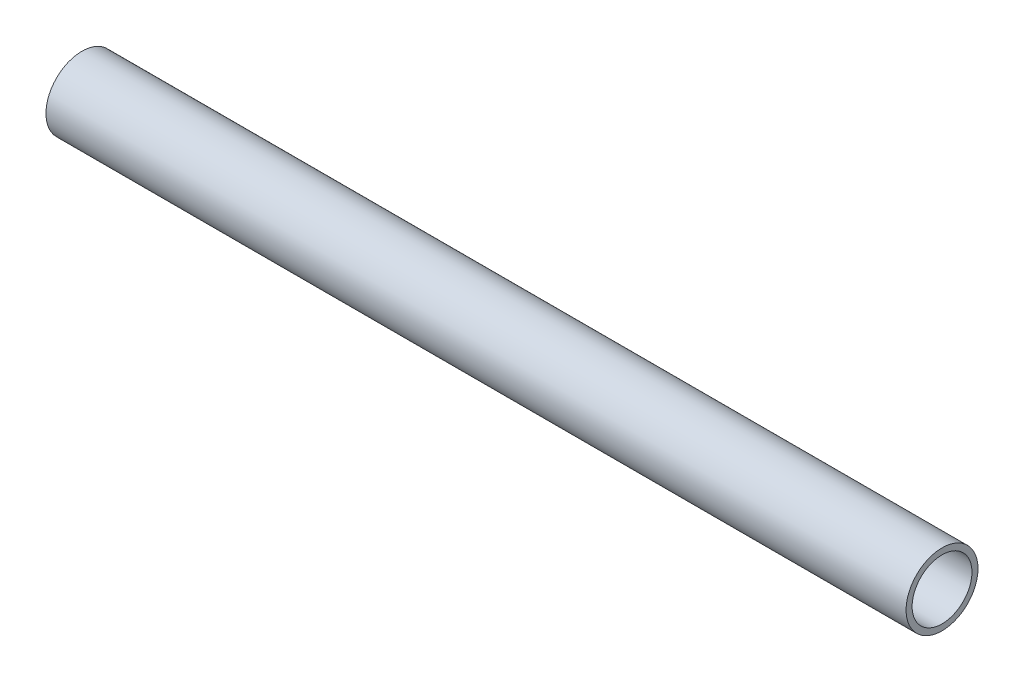
from build123d import *

# Parameters (mm, degrees)
SKETCH11_R              = 6.35
SKETCH11_R_2            = 5.2832
PIPE_0_5_SCH_40_1_DEPTH = 151.868904015


with BuildPart() as part:
    # Sketch11 → Pipe 0.5 SCH 40(1) (new body)
    with BuildSketch(Plane(origin=(-279.87171435, 1290.666264768, 0), x_dir=(0, 1, 0), z_dir=(1, 0, 0))):
        Circle(SKETCH11_R)
        Circle(SKETCH11_R_2, mode=Mode.SUBTRACT)
    extrude(amount=PIPE_0_5_SCH_40_1_DEPTH)


solid = part.part
